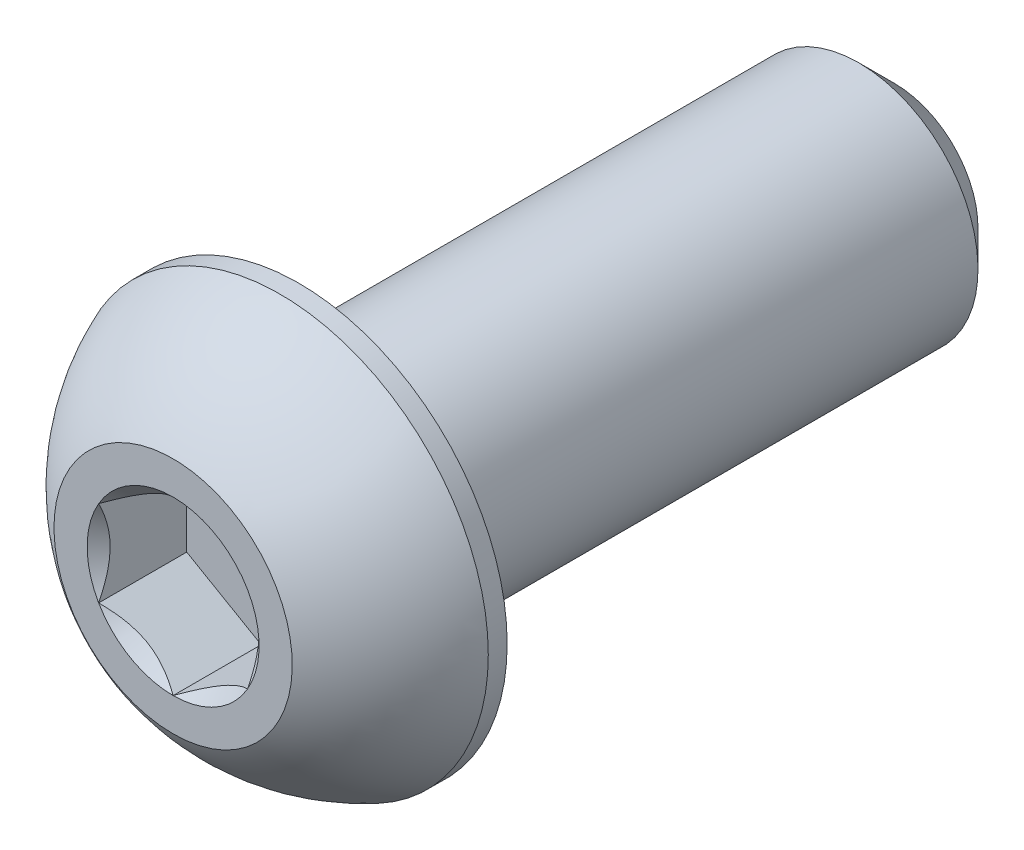
from build123d import *

# Parameters (mm, degrees)
SKETCH1_W          = 15.875
SKETCH1_H          = 3.175
CHAMFER1_SIZE      = 0.9525
CUT_EXTRUDE2_DEPTH = 2.34696


with BuildPart() as part:
    # Sketch1 → Revolve1 (revolve)
    with BuildSketch(Plane(origin=(0, 0, 0), x_dir=(0, 0, -1), z_dir=(1, 0, 0))):
        with Locations((11.2903, 1.5875)):
            Rectangle(SKETCH1_W, SKETCH1_H)
    revolve(axis=Axis((0, 0, -19.2278), (0, 0, 1)))

    # Chamfer1
    chamfer1_edges = [part.edges().sort_by_distance(p)[0] for p in [
        (0, -3.175, -19.2278),
    ]]
    chamfer(chamfer1_edges, length=CHAMFER1_SIZE)

    # Sketch7 → Revolve2 (revolve)
    with BuildSketch(Plane(origin=(0, 0, 0), x_dir=(0, 0, -1), z_dir=(1, 0, 0))):
        with BuildLine():
            Line((2.84988, 5.5499), (3.3528, 5.5499))
            Line((3.3528, 5.5499), (3.3528, 0))
            Line((3.3528, 0), (0, 0))
            Line((0, 0), (0, 3.175))
            ThreePointArc((0, 3.175), (1.235921075, 4.58927271), (2.84988, 5.5499))
        make_face()
    revolve(axis=Axis((0, 0, 0), (0, 0, -1)))

    # Sketch5 → Cut-Extrude2 (cut)
    with BuildSketch(Plane.XY):
        Polygon((1.984375, -1.14567944), (1.984375, 1.14567944), (0, 2.291358881), (-1.984375, 1.14567944), (-1.984375, -1.14567944), (0, -2.291358881), align=None)
    extrude(amount=-CUT_EXTRUDE2_DEPTH, mode=Mode.SUBTRACT)

    # Cut-Extrude3 cone 1 section (through the dimple's axis) → Cut-Extrude3 (revolve, cut)
    with BuildSketch(Plane(origin=(0, 0, 0), x_dir=(0, -1, 0), z_dir=(1, 0, 0))):
        Polygon((0, 0), (2.291358881, 0), (0, 2.291358881), align=None)
    revolve(axis=Axis((0, 0, 0), (0, 0, -1)), mode=Mode.SUBTRACT)


solid = part.part
